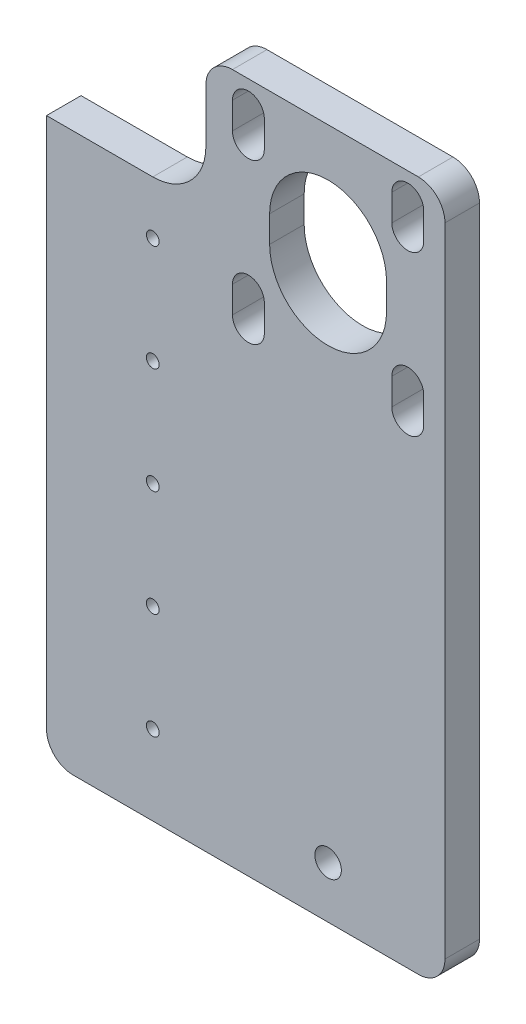
from build123d import *

# Parameters (mm, degrees)
SKETCH1_W                         = 37.5
SKETCH1_H                         = 130
MOUNTING_PLATE_DEPTH              = 6.5
MOTOR_MOUNT_DEPTH                 = 10
LPATTERN1_COUNT                   = 2
LPATTERN1_PITCH                   = 30
LPATTERN1_COUNT_DIR2              = 2
LPATTERN1_PITCH_DIR2              = 30
MOTOR_HOLE_DEPTH                  = 7.5
LIMIT_SWITCH_PLACEMENT_DEPTH      = 1
LIMIT_SWITCH_PLACEMENT_DEPTH_BACK = 7.5
SKETCH8_R                         = 1.2
SLIDE_HOLES_DEPTH                 = 7.5
LPATTERN2_COUNT                   = 5
LPATTERN2_PITCH                   = 20
FILLET1_R                         = 5
SKETCH16_R                        = 2.5
CUT_EXTRUDE1_DEPTH                = 7.5
M3X0_5_TAPPED_HOLE1_D             = 2.5
M3X0_5_TAPPED_HOLE1_DEPTH         = 7.5
M3X0_5_TAPPED_HOLE1_TIP           = 0.751075774


with BuildPart() as part:
    # Sketch1 → Mounting Plate (new body)
    with BuildSketch(Plane.XY):
        with Locations((-18.75, 65)):
            Rectangle(SKETCH1_W, SKETCH1_H)
        with Locations((18.75, 65)):
            Rectangle(SKETCH1_W, SKETCH1_H)
    extrude(amount=MOUNTING_PLATE_DEPTH)

    # Sketch3 → Motor Mount (cut)
    with BuildSketch(Plane.XY.offset(6.5)):
        with BuildLine():
            Line((-2.5, 120), (-2.5, 125))
            ThreePointArc((-2.5, 125), (0.5, 128), (3.5, 125))
            Line((3.5, 125), (3.5, 120))
            ThreePointArc((3.5, 120), (0.5, 117), (-2.5, 120))
        make_face()
    motor_mount = extrude(amount=-MOTOR_MOUNT_DEPTH, mode=Mode.SUBTRACT)

    # LPattern1: Motor Mount 2 × 2
    with Locations(*[(i * LPATTERN1_PITCH, -j * LPATTERN1_PITCH_DIR2, 0) for i in range(LPATTERN1_COUNT) for j in range(LPATTERN1_COUNT_DIR2) if (i, j) != (0, 0)]):
        add(motor_mount, mode=Mode.SUBTRACT)

    # Sketch7 → Motor Hole (cut, through all)
    with BuildSketch(Plane.XY.offset(6.5)):
        with BuildLine():
            Line((4.5, 105), (4.5, 110))
            ThreePointArc((4.5, 110), (15.5, 121), (26.5, 110))
            Line((26.5, 110), (26.5, 105))
            ThreePointArc((26.5, 105), (15.5, 94), (4.5, 105))
        make_face()
    extrude(amount=-MOTOR_HOLE_DEPTH, mode=Mode.SUBTRACT)

    # Sketch2 → Limit Switch Placement (cut, two sides)
    with BuildSketch(Plane.XY.offset(6.5)) as limit_switch_placement_sk:
        with BuildLine():
            Line((-7.5, 415.136329844), (-7.5, 130))
            Line((-7.5, 130), (-7.5, 115))
            ThreePointArc((-7.5, 115), (-10.428932188, 107.928932188), (-17.5, 105))
            Line((-17.5, 105), (-37.5, 105))
            Line((-37.5, 105), (-322.636329844, 105))
            Line((-322.636329844, 105), (-722.642663203, 511.455212366))
            Line((-722.642663203, 511.455212366), (-407.50633336, 821.59154221))
            Line((-407.50633336, 821.59154221), (-7.5, 415.136329844))
        make_face()
    extrude(amount=LIMIT_SWITCH_PLACEMENT_DEPTH, mode=Mode.SUBTRACT)
    extrude(limit_switch_placement_sk.sketch, amount=-LIMIT_SWITCH_PLACEMENT_DEPTH_BACK, mode=Mode.SUBTRACT)

    # Sketch8 → Slide Holes (cut, through all)
    with BuildSketch(Plane.XY.offset(6.5)):
        with Locations((-17.5, 95)):
            Circle(SKETCH8_R)
    slide_holes = extrude(amount=-SLIDE_HOLES_DEPTH, mode=Mode.SUBTRACT)

    # LPattern2: Slide Holes ×5
    with Locations(*[(0, -i * LPATTERN2_PITCH, 0) for i in range(1, LPATTERN2_COUNT)]):
        add(slide_holes, mode=Mode.SUBTRACT)

    # Fillet1
    fillet1_edges = [part.edges().sort_by_distance(p)[0] for p in [
        (37.5, 130, 3.25),
        (37.5, 0, 3.25),
        (-37.5, 0, 3.25),
        (-7.5, 130, 3.25),
    ]]
    fillet(fillet1_edges, radius=FILLET1_R)

    # Sketch16 → Cut-Extrude1 (cut, through all)
    with BuildSketch(Plane.XY.offset(6.5)):
        with Locations((15.5, 9.71)):
            Circle(SKETCH16_R)
    extrude(amount=-CUT_EXTRUDE1_DEPTH, mode=Mode.SUBTRACT)

    # M3x0.5 Tapped Hole1
    with Locations(Plane(origin=(0, 0, 0), x_dir=(-1, 0, 0), z_dir=(0, -1, 0))):
        with Locations((-18.5, -3.25), (-12.5, -3.25)):
            Hole(M3X0_5_TAPPED_HOLE1_D / 2, depth=M3X0_5_TAPPED_HOLE1_DEPTH)
            with Locations((0, 0, -(M3X0_5_TAPPED_HOLE1_DEPTH + M3X0_5_TAPPED_HOLE1_TIP / 2))):  # 118° drill point
                Cone(0, M3X0_5_TAPPED_HOLE1_D / 2, M3X0_5_TAPPED_HOLE1_TIP, mode=Mode.SUBTRACT)


solid = part.part
